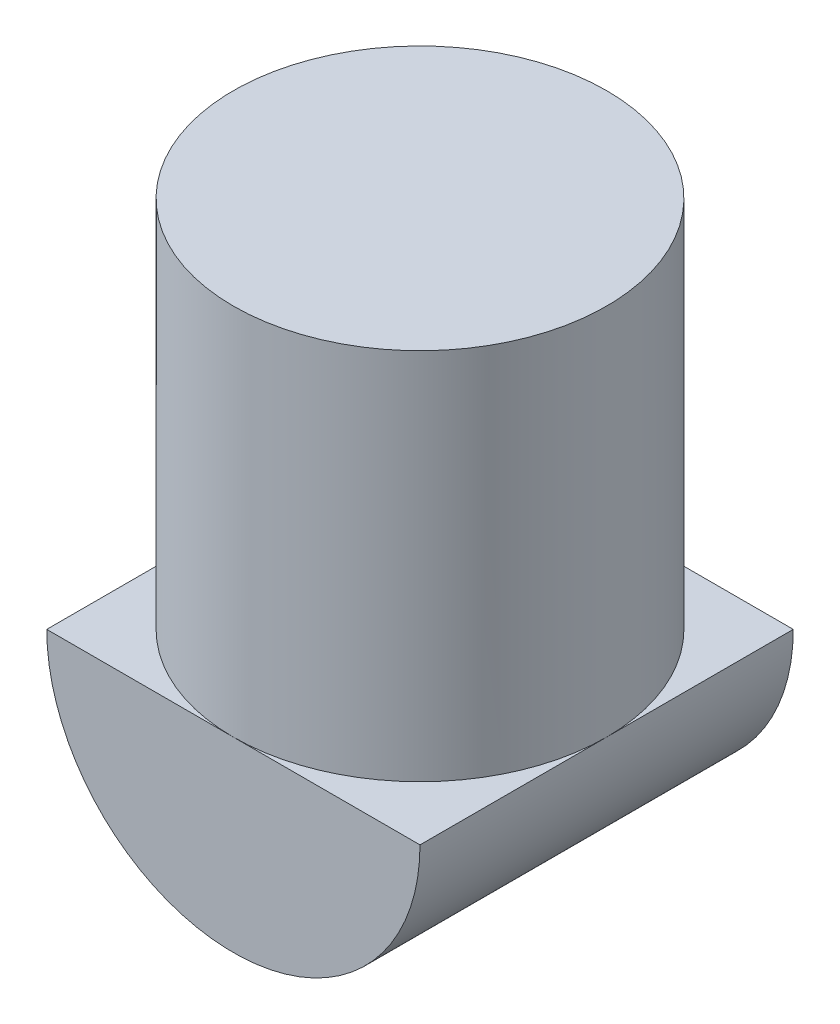
from build123d import *

# Parameters (mm, degrees)
EXTRUDE_1_DEPTH     = 16
SKETCH_2_W          = 18.798290213
SKETCH_2_H          = 18.208539932
SKETCH_2_R          = 8
CUT_EXTRUDE_1_DEPTH = 16


with BuildPart() as part:
    # 草图1 → 凸台-拉伸1 (new body)
    with BuildSketch(Plane.XY):
        with BuildLine():
            Line((-8, 0), (-8, 16))
            Line((-8, 16), (8, 16))
            Line((8, 16), (8, 0))
            ThreePointArc((8, 0), (0, -8), (-8, 0))
        make_face()
    extrude(amount=EXTRUDE_1_DEPTH)

    # 草图2 → 切除-拉伸1 (cut)
    with BuildSketch(Plane(origin=(0, 16, 0), x_dir=(1, 0, 0), z_dir=(0, 1, 0))):
        with Locations((-0.294875141, -7.797273341)):
            Rectangle(SKETCH_2_W, SKETCH_2_H)
        with Locations((0, -8)):
            Circle(SKETCH_2_R, mode=Mode.SUBTRACT)
    extrude(amount=-CUT_EXTRUDE_1_DEPTH, mode=Mode.SUBTRACT)


solid = part.part
